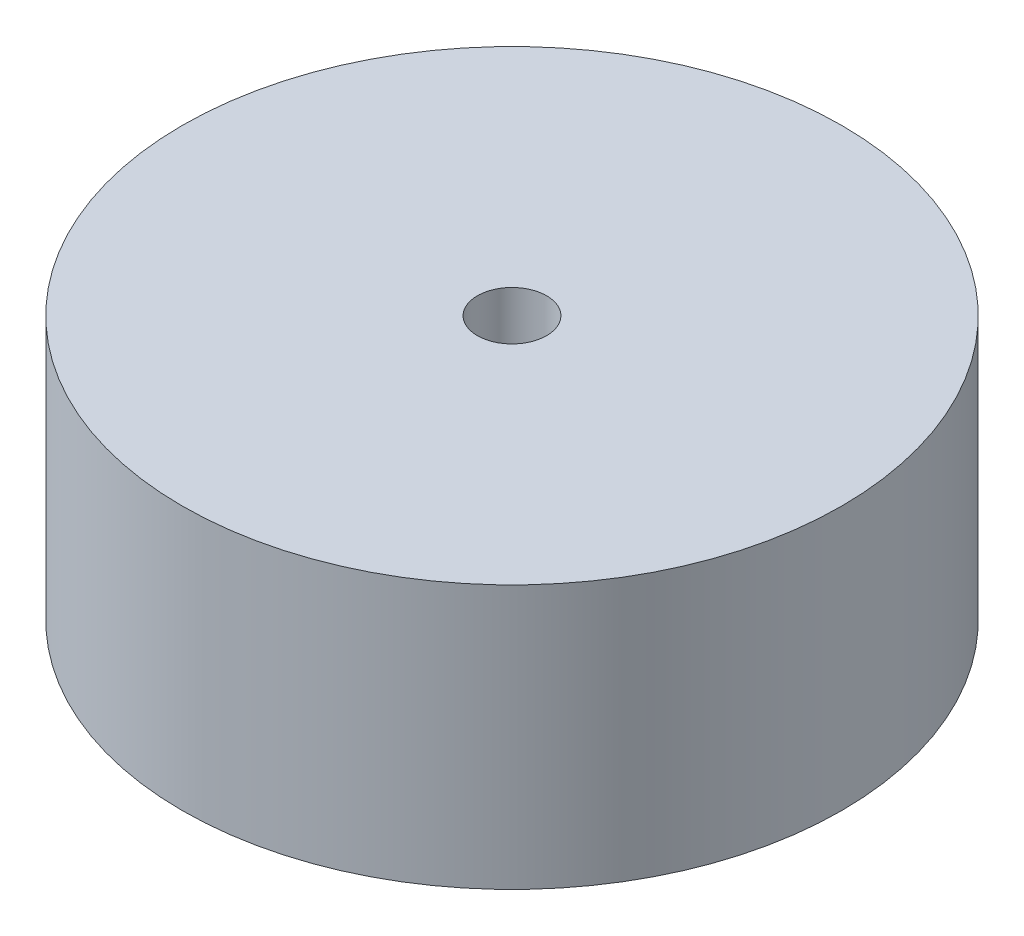
from build123d import *

# Parameters (mm, degrees)
SKETCH1_R           = 10
SKETCH1_R_2         = 1.05
BOSS_EXTRUDE1_DEPTH = 8


with BuildPart() as part:
    # Sketch1 → Boss-Extrude1 (new body)
    with BuildSketch(Plane(origin=(0, 0, 0), x_dir=(1, 0, 0), z_dir=(0, 1, 0))):
        Circle(SKETCH1_R)
        Circle(SKETCH1_R_2, mode=Mode.SUBTRACT)
    extrude(amount=BOSS_EXTRUDE1_DEPTH)


solid = part.part
